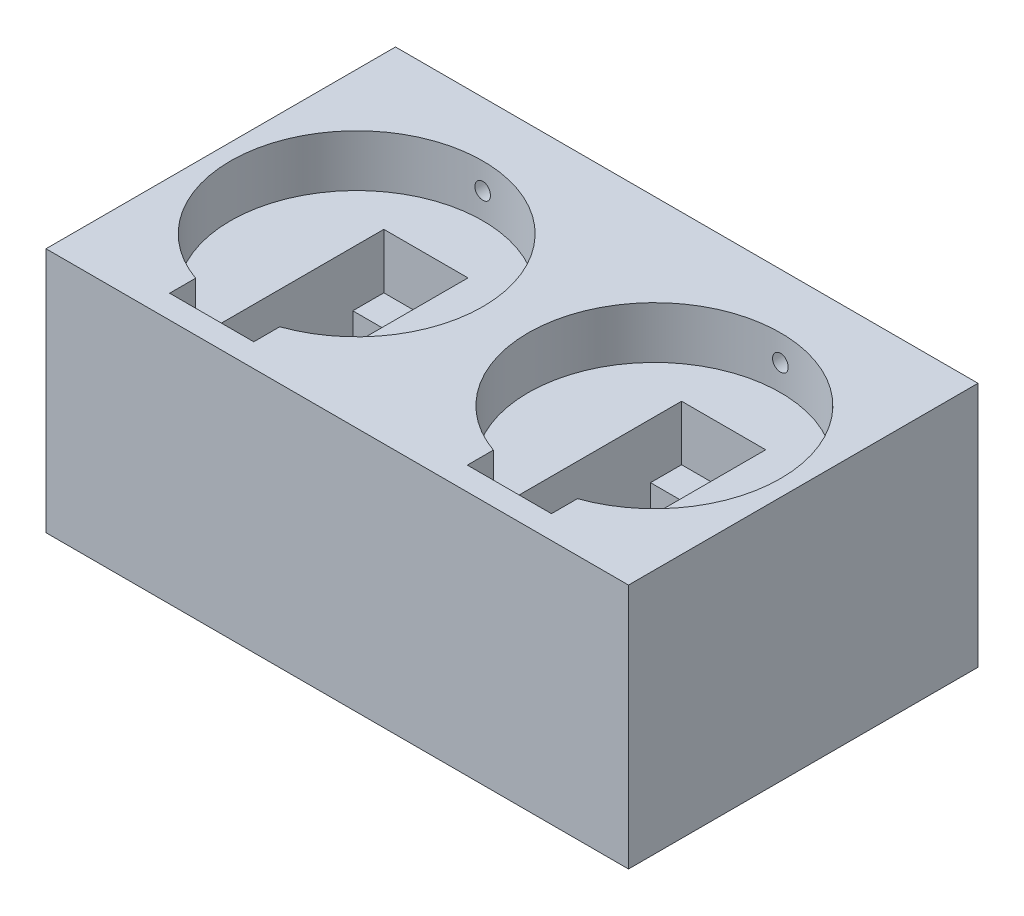
from build123d import *

# Parameters (mm, degrees)
SKETCH1_W                       = 90
SKETCH1_H                       = 54
BOSS_EXTRUDE1_DEPTH             = 38
CUT_EXTRUDE1_START              = -15.5
CUT_EXTRUDE1_DEPTH              = 13
SKETCH4_W                       = 13
SKETCH4_H                       = 4.8
CUT_EXTRUDE2_DEPTH              = 14
SKETCH3_R                       = 19.5
CUT_EXTRUDE3_DEPTH              = 8
SKETCH7_R                       = 1.5
CUT_EXTRUDE4_DEPTH              = 5
M5X0_8_TAPPED_HOLE1_D           = 4.2
M5X0_8_TAPPED_HOLE1_DEPTH       = 8
M5X0_8_TAPPED_HOLE1_CSINK_D     = 6
M5X0_8_TAPPED_HOLE1_CSINK_ANGLE = 90
M5X0_8_TAPPED_HOLE1_TIP         = 1.2618073


with BuildPart() as part:
    # Sketch1 → Boss-Extrude1 (new body)
    with BuildSketch(Plane(origin=(0, 0, 0), x_dir=(1, 0, 0), z_dir=(0, 1, 0))):
        Rectangle(SKETCH1_W, SKETCH1_H)
    extrude(amount=BOSS_EXTRUDE1_DEPTH)

    # Sketch2 → Cut-Extrude1 (cut)
    with BuildSketch(Plane.ZY.offset(45).offset(CUT_EXTRUDE1_START)):
        Polygon((-4.9, 2.5), (18.6, 2.5), (18.6, 21.5), (23.4, 21.5), (23.4, 24), (18.6, 24), (18.6, 37.402398481), (-4.9, 37.402398481), (-4.9, 24), (-9.7, 24), (-9.7, 21.5), (-4.9, 21.5), align=None)
    cut_extrude1 = extrude(amount=-CUT_EXTRUDE1_DEPTH, mode=Mode.SUBTRACT)

    # Sketch4 → Cut-Extrude2 (cut)
    with BuildSketch(Plane.XZ.offset(-24)):
        with Locations((-23, 21)):
            Rectangle(SKETCH4_W, SKETCH4_H)
        with Locations((-23, -7.3)):
            Rectangle(SKETCH4_W, SKETCH4_H)
    cut_extrude2 = extrude(amount=-CUT_EXTRUDE2_DEPTH, mode=Mode.SUBTRACT)

    # Sketch3 → Cut-Extrude3 (cut)
    with BuildSketch(Plane(origin=(0, 38, 0), x_dir=(1, 0, 0), z_dir=(0, 1, 0))):
        with Locations((-23, -1)):
            Circle(SKETCH3_R)
    cut_extrude3 = extrude(amount=-CUT_EXTRUDE3_DEPTH, mode=Mode.SUBTRACT)

    # Sketch7 → Cut-Extrude4 (cut)
    with BuildSketch(Plane(origin=(0, 21.5, 0), x_dir=(1, 0, 0), z_dir=(0, 1, 0))):
        with Locations((-23, 7.507766872)):
            Circle(SKETCH7_R)
        with Locations((-23, -19.255354552)):
            Circle(SKETCH7_R)
    cut_extrude4 = extrude(amount=-CUT_EXTRUDE4_DEPTH, mode=Mode.SUBTRACT)

    # Mirror1: Cut-Extrude1, Cut-Extrude2, Cut-Extrude3, Cut-Extrude4 across plane
    add(cut_extrude1.mirror(Plane(origin=(0, 0, 0), x_dir=(0, 0, 1), z_dir=(1, 0, 0))), mode=Mode.SUBTRACT)
    add(cut_extrude2.mirror(Plane(origin=(0, 0, 0), x_dir=(0, 0, 1), z_dir=(1, 0, 0))), mode=Mode.SUBTRACT)
    add(cut_extrude3.mirror(Plane(origin=(0, 0, 0), x_dir=(0, 0, 1), z_dir=(1, 0, 0))), mode=Mode.SUBTRACT)
    add(cut_extrude4.mirror(Plane(origin=(0, 0, 0), x_dir=(0, 0, 1), z_dir=(1, 0, 0))), mode=Mode.SUBTRACT)

    # M5x0.8 Tapped Hole1
    with Locations(Plane(origin=(23, 34, -27), x_dir=(-1, 0, 0), z_dir=(0, 0, -1))):
        with Locations((0, 0), (46, 0)):
            CounterSinkHole(M5X0_8_TAPPED_HOLE1_D / 2, M5X0_8_TAPPED_HOLE1_CSINK_D / 2, depth=M5X0_8_TAPPED_HOLE1_DEPTH, counter_sink_angle=M5X0_8_TAPPED_HOLE1_CSINK_ANGLE)
            with Locations((0, 0, -(M5X0_8_TAPPED_HOLE1_DEPTH + M5X0_8_TAPPED_HOLE1_TIP / 2))):  # 118° drill point
                Cone(0, M5X0_8_TAPPED_HOLE1_D / 2, M5X0_8_TAPPED_HOLE1_TIP, mode=Mode.SUBTRACT)


solid = part.part
